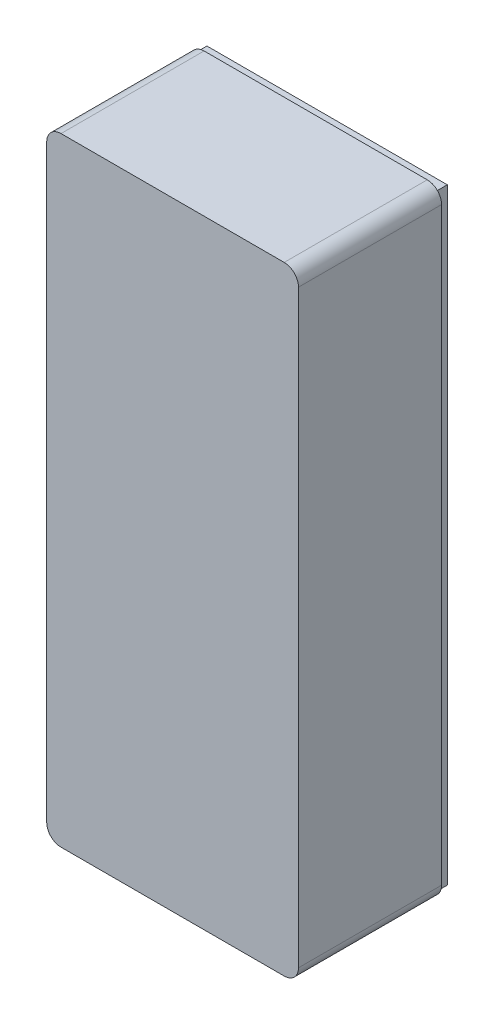
from build123d import *

# Parameters (mm, degrees)
SKICA1_W                 = 44
SKICA1_H                 = 108
SKICA1_W_2               = 40
SKICA1_H_2               = 104
P_IDAT_VYSUNUT_M1_DEPTH  = 25
SKICA2_W                 = 44
SKICA2_H                 = 108
P_IDAT_VYSUNUT_M2_DEPTH  = 2
ZAOBLIT1_R               = 2.5
SKICA3_W                 = 44
SKICA3_H                 = 108
SKICA3_W_2               = 42
SKICA3_H_2               = 106
ODEBRAT_VYSUNUT_M1_DEPTH = 2
SKICA4_R                 = 1.5
P_IDAT_VYSUNUT_M3_DEPTH  = 22
ODEBRAT_VYSUNUT_M2_DEPTH = 10
SKICA7_W                 = 40
SKICA7_H                 = 2
SKICA7_W_2               = 5
P_IDAT_VYSUNUT_M4_DEPTH  = 10
SKICA8_R                 = 0.95
SKICA8_W                 = 6
SKICA8_H                 = 12
ODEBRAT_VYSUNUT_M3_DEPTH = 10


with BuildPart() as part:
    # Skica1 → Přidat vysunutím1 (new body)
    with BuildSketch(Plane.XY):
        with Locations((22, 54)):
            Rectangle(SKICA1_W, SKICA1_H)
        with Locations((22, 54)):
            Rectangle(SKICA1_W_2, SKICA1_H_2, mode=Mode.SUBTRACT)
    extrude(amount=P_IDAT_VYSUNUT_M1_DEPTH)

    # Skica2 → Přidat vysunutím2 (add)
    with BuildSketch(Plane.XY.offset(25)):
        with Locations((22, 54)):
            Rectangle(SKICA2_W, SKICA2_H)
    extrude(amount=P_IDAT_VYSUNUT_M2_DEPTH)

    # Zaoblit1
    zaoblit1_edges = [part.edges().sort_by_distance(p)[0] for p in [
        (0, 108, 13.5),
        (44, 108, 13.5),
        (44, 0, 13.5),
        (0, 0, 13.5),
    ]]
    fillet(zaoblit1_edges, radius=ZAOBLIT1_R)

    # Skica3 → Odebrat vysunutím1 (cut)
    with BuildSketch(Plane(origin=(0, 0, 0), x_dir=(-1, 0, 0), z_dir=(0, 0, -1))):
        with Locations((-22, 54)):
            Rectangle(SKICA3_W, SKICA3_H)
        with Locations((-22, 54)):
            Rectangle(SKICA3_W_2, SKICA3_H_2, mode=Mode.SUBTRACT)
    extrude(amount=-ODEBRAT_VYSUNUT_M1_DEPTH, mode=Mode.SUBTRACT)

    # Skica4 → Přidat vysunutím3 (add)
    with BuildSketch(Plane(origin=(0, 0, 25), x_dir=(-1, 0, 0), z_dir=(0, 0, -1))):
        with BuildLine():
            Line((-42, 2), (-42, 10))
            ThreePointArc((-42, 10), (-36.343145751, 7.656854249), (-34, 2))
            Line((-34, 2), (-42, 2))
        make_face()
        with Locations((-39, 5)):
            Circle(SKICA4_R, mode=Mode.SUBTRACT)
        with BuildLine():
            Line((-2, 2), (-10, 2))
            ThreePointArc((-10, 2), (-7.656854249, 7.656854249), (-2, 10))
            Line((-2, 10), (-2, 2))
        make_face()
        with Locations((-5, 5)):
            Circle(SKICA4_R, mode=Mode.SUBTRACT)
        with BuildLine():
            Line((-2, 80), (-2, 76))
            Line((-2, 76), (-5, 76))
            ThreePointArc((-5, 76), (-9, 80), (-5, 84))
            Line((-5, 84), (-2, 84))
            Line((-2, 84), (-2, 80))
        make_face()
        with Locations((-5, 80)):
            Circle(SKICA4_R, mode=Mode.SUBTRACT)
        with BuildLine():
            Line((-42, 84), (-39, 84))
            ThreePointArc((-39, 84), (-35, 80), (-39, 76))
            Line((-39, 76), (-42, 76))
            Line((-42, 76), (-42, 84))
        make_face()
        with Locations((-39, 80)):
            Circle(SKICA4_R, mode=Mode.SUBTRACT)
    extrude(amount=P_IDAT_VYSUNUT_M3_DEPTH)

    # Skica6 → Odebrat vysunutím2 (cut)
    with BuildSketch(Plane.XZ):
        Polygon((22, 10.4), (15.25, 10.4), (15.25, 5), (28.75, 5), (28.75, 10.4), align=None)
    extrude(amount=-ODEBRAT_VYSUNUT_M2_DEPTH, mode=Mode.SUBTRACT)

    # Skica7 → Přidat vysunutím4 (add)
    with BuildSketch(Plane(origin=(0, 0, 25), x_dir=(-1, 0, 0), z_dir=(0, 0, -1))):
        with Locations((-22, 15)):
            Rectangle(SKICA7_W, SKICA7_H)
        with Locations((-39.5, 64.682971934)):
            Rectangle(SKICA7_W_2, SKICA7_H)
    extrude(amount=P_IDAT_VYSUNUT_M4_DEPTH)

    # Skica8 → Odebrat vysunutím3 (cut)
    with BuildSketch(Plane.ZY):
        with Locations((12.5, 35.5)):
            Circle(SKICA8_R)
        with Locations((12.5, 20.5)):
            Circle(SKICA8_R)
        with Locations((12.5, 28)):
            Rectangle(SKICA8_W, SKICA8_H)
    extrude(amount=-ODEBRAT_VYSUNUT_M3_DEPTH, mode=Mode.SUBTRACT)


solid = part.part
